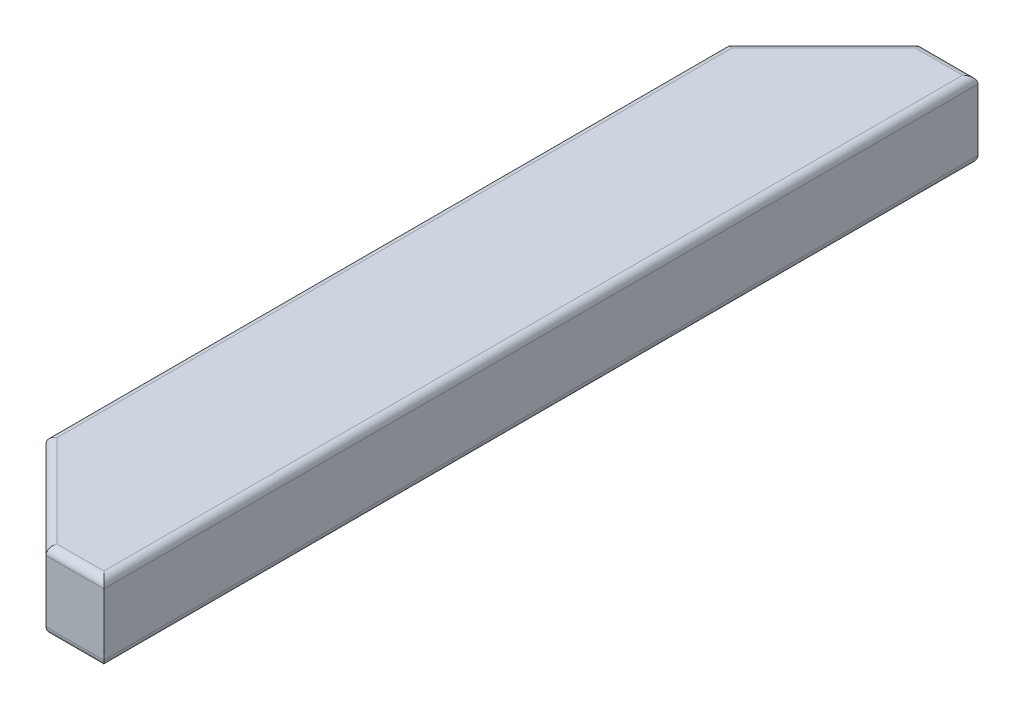
from build123d import *

# Parameters (mm, degrees)
SKETCH2_W           = 101.6
SKETCH2_H           = 50.8
BOSS_EXTRUDE1_DEPTH = 575.4
CUT_EXTRUDE1_DEPTH  = 51.8
FILLET1_R           = 5.08


with BuildPart() as part:
    # Sketch2 → Boss-Extrude1 (new body)
    with BuildSketch(Plane(origin=(0, 0, 287.7), x_dir=(-1, 0, 0), z_dir=(0, 0, -1))):
        with Locations((-2663.5, 12.7)):
            Rectangle(SKETCH2_W, SKETCH2_H)
    extrude(amount=BOSS_EXTRUDE1_DEPTH)

    # Sketch5 → Cut-Extrude1 (cut, through all)
    with BuildSketch(Plane(origin=(0, 38.1, 0), x_dir=(1, 0, 0), z_dir=(0, 1, 0))):
        Polygon((2612.7, -287.7), (2676.2, -287.7), (2612.7, -224.2), align=None)
        Polygon((2676.2, 287.7), (2612.7, 224.2), (2612.7, 287.7), align=None)
    extrude(amount=-CUT_EXTRUDE1_DEPTH, mode=Mode.SUBTRACT)

    # Fillet1
    fillet1_edges = [part.edges().sort_by_distance(p)[0] for p in [
        (2714.3, 38.1, 0),
        (2695.25, 38.1, -287.7),
        (2714.3, -12.7, 0),
        (2695.25, -12.7, -287.7),
        (2612.7, -12.7, 0),
        (2612.7, 38.1, 0),
        (2695.25, 38.1, 287.7),
        (2644.45, -12.7, -255.95),
        (2644.45, 38.1, -255.95),
        (2644.45, -12.7, 255.95),
        (2644.45, 38.1, 255.95),
        (2695.25, -12.7, 287.7),
    ]]
    fillet(fillet1_edges, radius=FILLET1_R)


solid = part.part
